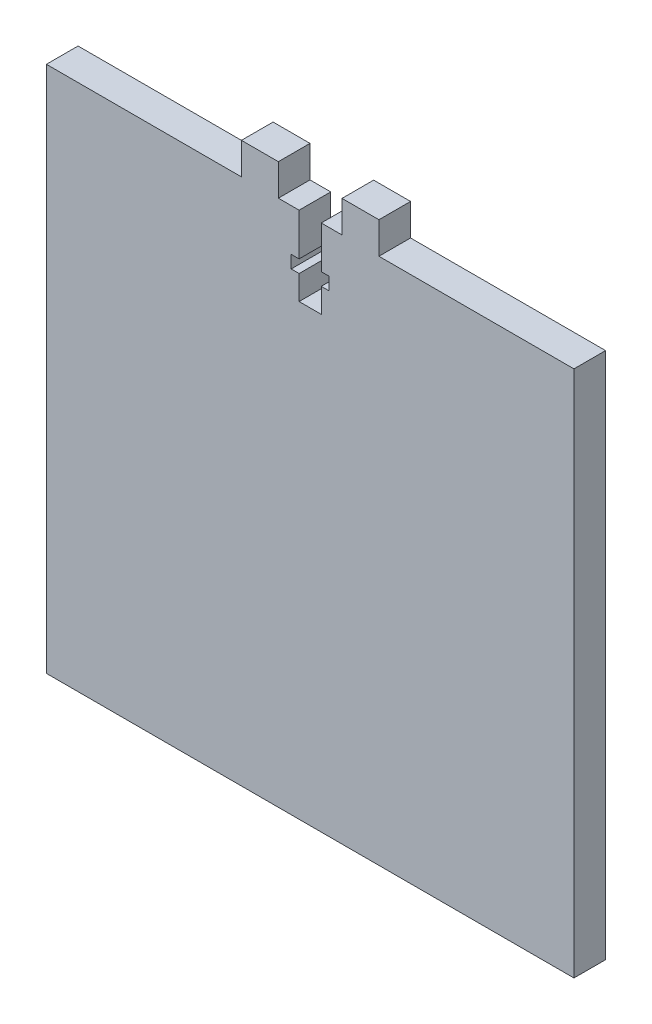
from build123d import *

# Parameters (mm, degrees)
SKETCH_1_W          = 100
SKETCH_1_H          = 100
EXTRUDE_1_DEPTH     = 6
SKETCH_2_W          = 7
SKETCH_2_H          = 6
EXTRUDE_2_DEPTH     = 6
CUT_EXTRUDE_1_DEPTH = 7


with BuildPart() as part:
    # Эскиз1 → Бобышка-Вытянуть1 (new body)
    with BuildSketch(Plane.XY):
        Rectangle(SKETCH_1_W, SKETCH_1_H)
    extrude(amount=EXTRUDE_1_DEPTH)

    # Эскиз2 → Бобышка-Вытянуть2 (add)
    with BuildSketch(Plane.XY.offset(6)):
        with Locations((-9.531849908, 53)):
            Rectangle(SKETCH_2_W, SKETCH_2_H)
        with Locations((9.531849908, 53)):
            Rectangle(SKETCH_2_W, SKETCH_2_H)
    extrude(amount=-EXTRUDE_2_DEPTH)

    # Эскиз3 → Вырез-Вытянуть1 (cut, through all)
    with BuildSketch(Plane.XY.offset(6)):
        Polygon((-2.1, 42), (-3.6, 42), (-3.6, 39.6), (-2.1, 39.6), (-2.1, 35), (2.1, 35), (2.1, 39.6), (3.6, 39.6), (3.6, 42), (2.1, 42), (2.1, 50), (-2.1, 50), align=None)
    extrude(amount=-CUT_EXTRUDE_1_DEPTH, mode=Mode.SUBTRACT)


solid = part.part
